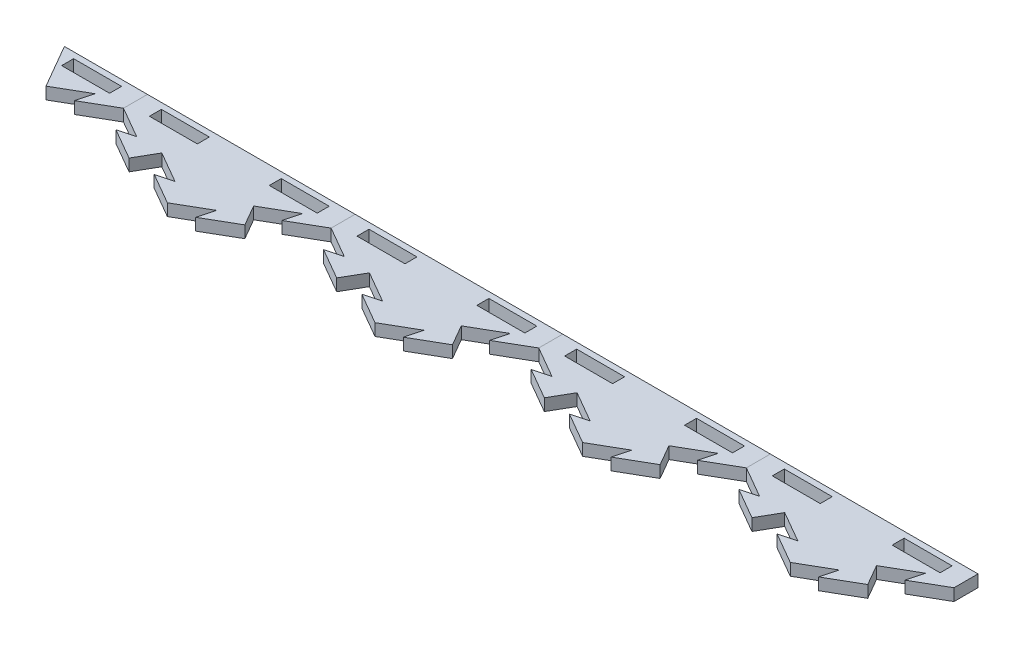
from build123d import *

# Parameters (mm, degrees)
BOSS_EXTRUDE1_DEPTH = 6.35
CUT_EXTRUDE4_DEPTH  = 111.168382488
BOSS_EXTRUDE4_DEPTH = 6.35
CIRPATTERN1_COUNT   = 2
CIRPATTERN1_ANGLE   = 60
SKETCH12_W          = 109.98522628
SKETCH12_H          = 82.55
CUT_EXTRUDE5_DEPTH  = 111.168382488
SKETCH13_W          = 25.4
SKETCH13_H          = 6.35
CUT_EXTRUDE6_DEPTH  = 64.816710194
LPATTERN1_COUNT     = 5
LPATTERN1_PITCH     = 109.985226308
LPATTERN1_2_COUNT   = 2
LPATTERN1_2_PITCH   = 109.985226308
SKETCH14_W          = 25.4
SKETCH14_H          = 6.35
CUT_EXTRUDE7_DEPTH  = 496.991504573
SKETCH15_W          = 43.994090512
SKETCH15_H          = 34.074261314
CUT_EXTRUDE8_DEPTH  = 431.162704792


with BuildPart() as part:
    # Sketch1 → Boss-Extrude1 (new body)
    with BuildSketch(Plane(origin=(0, 0, 0), x_dir=(1, 0, 0), z_dir=(0, 1, 0))):
        Polygon((-54.99261314, 0), (0, -31.75), (54.99261314, 0), (54.99261314, 63.5), (0, 95.25), (-54.99261314, 63.5), align=None)
    extrude(amount=-BOSS_EXTRUDE1_DEPTH)

    # Sketch10 → Cut-Extrude4 (cut, through all)
    with BuildSketch(Plane(origin=(0, 0, 0), x_dir=(1, 0, 0), z_dir=(0, 1, 0))):
        Polygon((-16.497783942, -22.225), (-7.823522628, -19.900738686), (-24.32130657, -10.375738686), (-27.49630657, -15.875), align=None)
    cut_extrude4 = extrude(amount=-CUT_EXTRUDE4_DEPTH, mode=Mode.SUBTRACT)

    # Sketch11 → Boss-Extrude4 (add)
    with BuildSketch(Plane(origin=(0, 0, 0), x_dir=(1, 0, 0), z_dir=(0, 1, 0))):
        Polygon((-27.49630657, -15.875), (-30.67130657, -21.374261314), (-47.169090512, -11.849261314), (-38.494829198, -9.525), align=None)
    boss_extrude4 = extrude(amount=-BOSS_EXTRUDE4_DEPTH)

    # CirPattern1: Cut-Extrude4, Boss-Extrude4 ×2 about axis
    cirpattern1_axis = Axis((0, 0, -31.75), (0, 1, 0))
    add([cut_extrude4.rotate(cirpattern1_axis, i * CIRPATTERN1_ANGLE / (CIRPATTERN1_COUNT - 1)) for i in range(1, CIRPATTERN1_COUNT)], mode=Mode.SUBTRACT)
    add([boss_extrude4.rotate(cirpattern1_axis, i * CIRPATTERN1_ANGLE / (CIRPATTERN1_COUNT - 1)) for i in range(1, CIRPATTERN1_COUNT)])

    # Sketch12 → Cut-Extrude5 (cut, through all)
    with BuildSketch(Plane(origin=(0, 0, 0), x_dir=(1, 0, 0), z_dir=(0, 1, 0))):
        with Locations((0, 53.975)):
            Rectangle(SKETCH12_W, SKETCH12_H)
    extrude(amount=-CUT_EXTRUDE5_DEPTH, mode=Mode.SUBTRACT)

    # Sketch13 → Cut-Extrude6 (cut, through all)
    with BuildSketch(Plane(origin=(0, 0, 0), x_dir=(1, 0, 0), z_dir=(0, 1, 0))):
        with Locations((-31.75, 6.35)):
            Rectangle(SKETCH13_W, SKETCH13_H)
        with Locations((31.75, 6.35)):
            Rectangle(SKETCH13_W, SKETCH13_H)
    extrude(amount=-CUT_EXTRUDE6_DEPTH, mode=Mode.SUBTRACT)


with BuildPart() as lpattern1_1:
    # LPattern1: pattern copy
    add(part.part.moved(Location(Vector(1, 0, 0) * (1 * LPATTERN1_PITCH))))


with BuildPart() as lpattern1_2:
    # LPattern1: pattern copy
    add(part.part.moved(Location(Vector(1, 0, 0) * (2 * LPATTERN1_PITCH))))


with BuildPart() as lpattern1_3:
    # LPattern1: pattern copy
    add(part.part.moved(Location(Vector(1, 0, 0) * (3 * LPATTERN1_PITCH))))


with BuildPart() as lpattern1_4:
    # LPattern1: pattern copy
    add(part.part.moved(Location(Vector(1, 0, 0) * (4 * LPATTERN1_PITCH))))


with BuildPart() as lpattern1_2_1:
    # LPattern1 2: pattern copy
    add(part.part.moved(Location(Vector(-1, 0, 0) * (1 * LPATTERN1_2_PITCH))))


with BuildPart() as cut_extrude7_tool:
    # Sketch14 → Cut-Extrude7 (new, through all)
    # profile 1 of 2: a face of its own
    with BuildSketch(Plane(origin=(0, 0, 0), x_dir=(1, 0, 0), z_dir=(0, 1, 0))):
        Polygon((423.44312129, -22.225), (439.940905232, -31.75), (456.438689174, -22.225), (454.11442786, -30.899261314), (470.612211802, -21.374261314), (464.262211802, -10.375738686), (480.759995744, -0.850738686), (478.43573443, -9.525), (494.933518372, 0), (494.933518372, 12.7), (428.942382604, 12.7), (415.619598662, -10.375738686), (432.117382604, -19.900738686), align=None)
        with Locations((471.690905232, 6.35)):
            Rectangle(SKETCH14_W, SKETCH14_H, mode=Mode.SUBTRACT)
    # profile 2 of 2: a face of its own
    with BuildSketch(Plane(origin=(0, 0, 0), x_dir=(1, 0, 0), z_dir=(0, 1, 0))):
        Polygon((-164.977839448, -31.75), (-109.985226308, -31.75), (-95.81170368, -30.899261314), (-79.313919738, -21.374261314), (-98.98670368, 12.7), (-164.977839448, 12.7), align=None)
    extrude(amount=-CUT_EXTRUDE7_DEPTH)


with BuildPart() as lpattern1_4_1:
    add(lpattern1_4.part)

    # Cut-Extrude7: cut by cut_extrude7_tool
    add(cut_extrude7_tool.part, mode=Mode.SUBTRACT)

    # Sketch15 → Cut-Extrude8 (cut, through all)
    with BuildSketch(Plane(origin=(0, 0, 0), x_dir=(1, 0, 0), z_dir=(0, 1, 0))):
        with Locations((406.945337348, -4.337130657)):
            Rectangle(SKETCH15_W, SKETCH15_H)
    extrude(amount=-CUT_EXTRUDE8_DEPTH, mode=Mode.SUBTRACT)


with BuildPart() as lpattern1_2_1_1:
    add(lpattern1_2_1.part)

    # Cut-Extrude7: cut by cut_extrude7_tool
    add(cut_extrude7_tool.part, mode=Mode.SUBTRACT)


solid = Compound([part.part, lpattern1_1.part, lpattern1_2.part, lpattern1_3.part, lpattern1_2_1_1.part])
